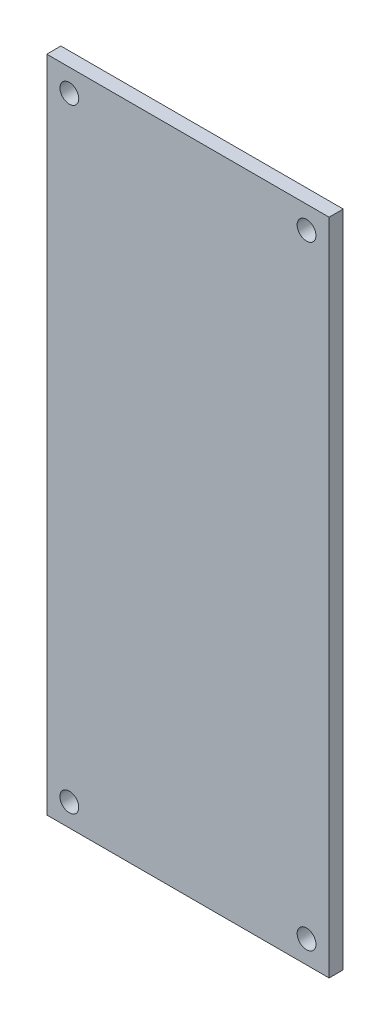
from build123d import *

# Parameters (mm, degrees)
SKETCH1_W           = 30
SKETCH1_H           = 70
SKETCH1_R           = 1
BOSS_EXTRUDE1_DEPTH = 1.5


with BuildPart() as part:
    # Sketch1 → Boss-Extrude1 (new body)
    with BuildSketch(Plane.XY):
        Rectangle(SKETCH1_W, SKETCH1_H)
        with Locations((-12.6, 32.6)):
            Circle(SKETCH1_R, mode=Mode.SUBTRACT)
        with Locations((12.6, 32.6)):
            Circle(SKETCH1_R, mode=Mode.SUBTRACT)
        with Locations((12.6, -32.6)):
            Circle(SKETCH1_R, mode=Mode.SUBTRACT)
        with Locations((-12.6, -32.6)):
            Circle(SKETCH1_R, mode=Mode.SUBTRACT)
    extrude(amount=BOSS_EXTRUDE1_DEPTH)


solid = part.part
